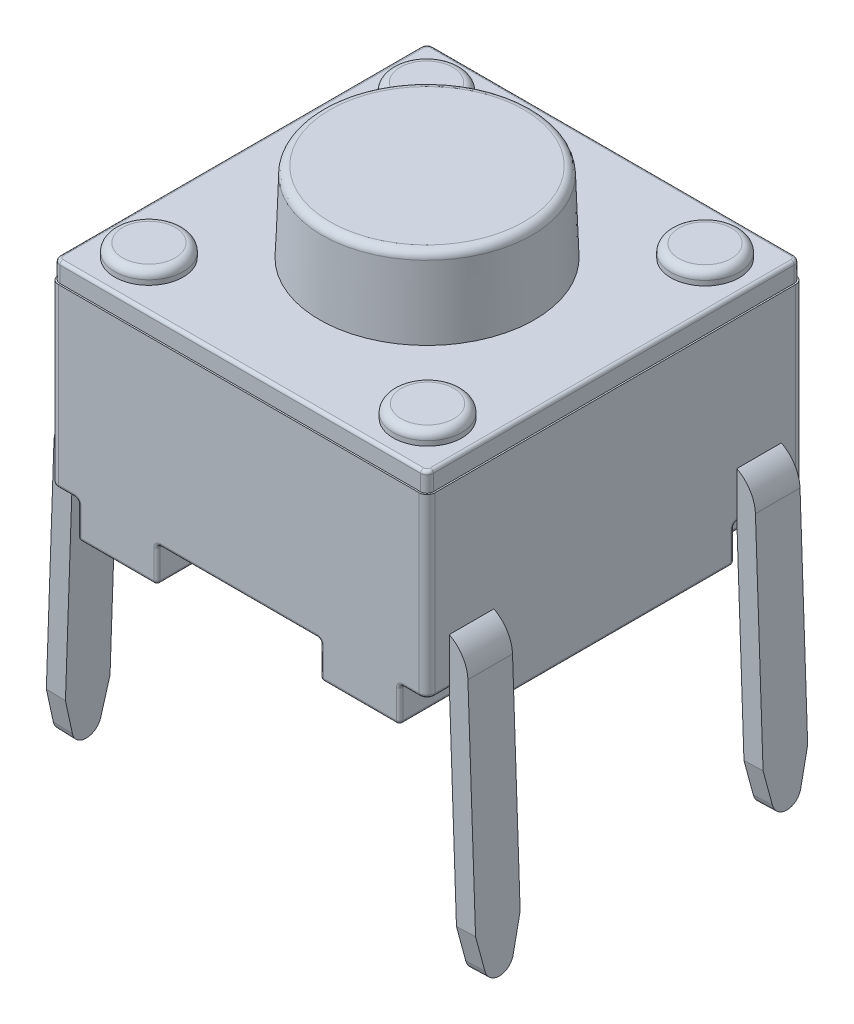
from build123d import *

# Parameters (mm, degrees)
BOSS_EXTRUDE1_START  = 0.5588
SKETCH1_W            = 6.0071
SKETCH1_H            = 6.0071
BOSS_EXTRUDE1_DEPTH  = 2.8194
FILLET1_R            = 0.127
BOSS_EXTRUDE2_DEPTH  = 0.3048
BOSS_EXTRUDE3_REACH  = 7.622
SKETCH4_R            = 0.5461
BOSS_EXTRUDE4_DEPTH  = 0.2032
SKETCH5_R            = 1.7145
BOSS_EXTRUDE5_DEPTH  = 1.27
BOSS_EXTRUDE5_TAPER  = 2
FILLET2_R            = 0.127
FILLET3_R            = 0.0508
EXTRUDE_THIN1_START  = -0.3556
EXTRUDE_THIN1_DEPTH  = 0.7112
CUT_EXTRUDE1_DEPTH   = 0.7112
MIRROR3_START        = -0.3556
MIRROR3_COPY_1_DEPTH = 0.7112
MIRROR3_COPY_2_DEPTH = 0.7112


with BuildPart() as part:
    # Sketch1 → Boss-Extrude1 (new body)
    with BuildSketch(Plane(origin=(0, 0, 0), x_dir=(1, 0, 0), z_dir=(0, 1, 0)).offset(BOSS_EXTRUDE1_START)):
        Rectangle(SKETCH1_W, SKETCH1_H)
    extrude(amount=BOSS_EXTRUDE1_DEPTH)

    # Fillet1
    fillet1_edges = [part.edges().sort_by_distance(p)[0] for p in [
        (3.00355, 1.9685, 3.00355),
        (-3.00355, 1.9685, 3.00355),
        (-3.00355, 1.9685, -3.00355),
        (3.00355, 1.9685, -3.00355),
    ]]
    fillet(fillet1_edges, radius=FILLET1_R)

    # Sketch2 → Boss-Extrude2 (add)
    with BuildSketch(Plane(origin=(0, 3.3782, 0), x_dir=(-1, 0, 0), z_dir=(0, -1, 0))):
        with BuildLine():
            Line((2.97815, -2.87655), (2.97815, 2.87655))
            ThreePointArc((2.97815, 2.87655), (2.948392049, 2.948392049), (2.87655, 2.97815))
            Line((2.87655, 2.97815), (-2.87655, 2.97815))
            ThreePointArc((-2.87655, 2.97815), (-2.948392049, 2.948392049), (-2.97815, 2.87655))
            Line((-2.97815, 2.87655), (-2.97815, -2.87655))
            ThreePointArc((-2.97815, -2.87655), (-2.948392049, -2.948392049), (-2.87655, -2.97815))
            Line((-2.87655, -2.97815), (2.87655, -2.97815))
            ThreePointArc((2.87655, -2.97815), (2.948392049, -2.948392049), (2.97815, -2.87655))
        make_face()
    extrude(amount=-BOSS_EXTRUDE2_DEPTH)

    # Sketch3 → Boss-Extrude3 (add, up to next)
    with BuildSketch(Plane(origin=(0, 0, 0), x_dir=(1, 0, 0), z_dir=(0, 1, 0)), mode=Mode.PRIVATE) as boss_extrude3_sk1:
        Polygon((-2.566197678, -3.00355), (-2.566197678, -1.89483443), (-3.00355, -1.89483443), (-3.00355, 1.89483443), (-2.566197678, 1.89483443), (-2.566197678, 3.00355), (-1.30175, 3.00355), (-1.30175, 0.560941661), (-2.441300776, 0.560941661), (-2.441300776, -0.560941661), (-1.30175, -0.560941661), (-1.30175, -3.00355), align=None)
    boss_extrude3_tool1 = extrude(boss_extrude3_sk1.sketch, amount=BOSS_EXTRUDE3_REACH, mode=Mode.PRIVATE) - part.part
    # Sketch3 → Boss-Extrude3 (add, up to next)
    with BuildSketch(Plane(origin=(0, 0, 0), x_dir=(1, 0, 0), z_dir=(0, 1, 0)), mode=Mode.PRIVATE) as boss_extrude3_sk2:
        Polygon((2.566197678, 3.00355), (2.566197678, 1.89483443), (3.00355, 1.89483443), (3.00355, -1.89483443), (2.566197678, -1.89483443), (2.566197678, -3.00355), (1.30175, -3.00355), (1.30175, -0.560941661), (2.441300776, -0.560941661), (2.441300776, 0.560941661), (1.30175, 0.560941661), (1.30175, 3.00355), align=None)
    boss_extrude3_tool2 = extrude(boss_extrude3_sk2.sketch, amount=BOSS_EXTRUDE3_REACH, mode=Mode.PRIVATE) - part.part
    add(boss_extrude3_tool1.solids().sort_by_distance((-2.503763, 0, 2.449192))[0])
    add(boss_extrude3_tool2.solids().sort_by_distance((2.503763, 0, -2.449192))[0])

    # Sketch4 → Boss-Extrude4 (add)
    with BuildSketch(Plane(origin=(0, 3.683, 0), x_dir=(1, 0, 0), z_dir=(0, 1, 0))):
        with Locations(Location((2.221694311, 2.212885437, 0), (0, 0, 90))):
            Circle(SKETCH4_R)
        with Locations(Location((-2.221694311, 2.212885437, 0), (0, 0, 90))):
            Circle(SKETCH4_R)
        with Locations(Location((-2.221694311, -2.212885437, 0), (0, 0, 90))):
            Circle(SKETCH4_R)
        with Locations(Location((2.221694311, -2.212885437, 0), (0, 0, 90))):
            Circle(SKETCH4_R)
    extrude(amount=BOSS_EXTRUDE4_DEPTH)

    # Sketch5 → Boss-Extrude5 (add)
    with BuildSketch(Plane(origin=(0, 3.683, 0), x_dir=(1, 0, 0), z_dir=(0, 1, 0))):
        Circle(SKETCH5_R)
    extrude(amount=BOSS_EXTRUDE5_DEPTH, taper=BOSS_EXTRUDE5_TAPER)

    # Fillet2
    fillet2_edges = [part.edges().sort_by_distance(p)[0] for p in [
        (2.221694311, 3.8862, -1.666785437),
        (-2.221694311, 3.8862, -1.666785437),
        (-2.221694311, 3.8862, 2.758985437),
        (2.221694311, 3.8862, 2.758985437),
        (-1.670150623, 4.953, 0),
    ]]
    fillet(fillet2_edges, radius=FILLET2_R)

    # Fillet3
    fillet3_edges = [part.edges().sort_by_distance(p)[0] for p in [
        (1.30175, 0.5588, -1.782245831),
        (1.30175, 0.2794, -3.00355),
        (1.30175, 0, -1.782245831),
        (1.871525388, 0.5588, -0.560941661),
        (1.30175, 0.2794, -0.560941661),
        (1.871525388, 0, -0.560941661),
        (2.441300776, 0.5588, 0),
        (2.441300776, 0.2794, -0.560941661),
        (2.441300776, 0, 0),
        (1.871525388, 0.5588, 0.560941661),
        (2.441300776, 0.2794, 0.560941661),
        (1.871525388, 0, 0.560941661),
        (1.30175, 0.5588, 1.782245831),
        (1.30175, 0.2794, 0.560941661),
        (1.30175, 0, 1.782245831),
        (1.30175, 0.2794, 3.00355),
        (1.933973839, 0, 3.00355),
        (2.566197678, 0.5588, 2.449192215),
        (2.566197678, 0.2794, 3.00355),
        (2.566197678, 0, 2.449192215),
        (2.784873839, 0.5588, 1.89483443),
        (2.566197678, 0.2794, 1.89483443),
        (2.784873839, 0, 1.89483443),
        (3.00355, 0.2794, 1.89483443),
        (3.00355, 0, 0),
        (2.784873839, 0.5588, -1.89483443),
        (3.00355, 0.2794, -1.89483443),
        (2.784873839, 0, -1.89483443),
        (2.566197678, 0.2794, -3.00355),
        (1.933973839, 0, -3.00355),
        (2.566197678, 0.5588, -2.449192215),
        (2.566197678, 0.2794, -1.89483443),
        (2.566197678, 0, -2.449192215),
        (-2.721373839, 0.5588, 3.00355),
        (3.00355, 0.5588, 2.385692215),
        (-3.00355, 0.5588, -2.385692215),
        (2.721373839, 0.5588, -3.00355),
        (2.966352561, 0.5588, 2.966352561),
        (2.966352561, 0.5588, -2.966352561),
        (-2.966352561, 0.5588, -2.966352561),
        (-2.966352561, 0.5588, 2.966352561),
        (-2.948392049, 3.683, 2.948392049),
        (0, 3.683, 2.97815),
        (2.948392049, 3.683, 2.948392049),
        (2.97815, 3.683, 0),
        (2.948392049, 3.683, -2.948392049),
        (0, 3.683, -2.97815),
        (-2.948392049, 3.683, -2.948392049),
        (-2.97815, 3.683, 0),
        (0, 0.5588, 3.00355),
        (-3.00355, 0.5588, 2.385692215),
        (-2.721373839, 0.5588, -3.00355),
        (-1.30175, 0.5588, 1.782245831),
        (-1.30175, 0.2794, 3.00355),
        (-1.30175, 0, 1.782245831),
        (-1.871525388, 0.5588, 0.560941661),
        (-1.30175, 0.2794, 0.560941661),
        (-1.871525388, 0, 0.560941661),
        (-2.441300776, 0.5588, 0),
        (-2.441300776, 0.2794, 0.560941661),
        (-2.441300776, 0, 0),
        (-1.871525388, 0.5588, -0.560941661),
        (-2.441300776, 0.2794, -0.560941661),
        (-1.871525388, 0, -0.560941661),
        (-1.30175, 0.5588, -1.782245831),
        (-1.30175, 0.2794, -0.560941661),
        (-1.30175, 0, -1.782245831),
        (-1.30175, 0.2794, -3.00355),
        (-1.933973839, 0, -3.00355),
        (-2.566197678, 0.5588, -2.449192215),
        (-2.566197678, 0.2794, -3.00355),
        (-2.566197678, 0, -2.449192215),
        (-2.784873839, 0.5588, -1.89483443),
        (-2.566197678, 0.2794, -1.89483443),
        (-2.784873839, 0, -1.89483443),
        (-3.00355, 0.2794, -1.89483443),
        (-3.00355, 0, 0),
        (-2.784873839, 0.5588, 1.89483443),
        (-3.00355, 0.2794, 1.89483443),
        (-2.784873839, 0, 1.89483443),
        (-2.566197678, 0.2794, 3.00355),
        (-1.933973839, 0, 3.00355),
        (-2.566197678, 0.5588, 2.449192215),
        (-2.566197678, 0.2794, 1.89483443),
        (-2.566197678, 0, 2.449192215),
        (0, 0.5588, -3.00355),
        (3.00355, 0.5588, -2.385692215),
        (2.721373839, 0.5588, 3.00355),
    ]]
    fillet(fillet3_edges, radius=FILLET3_R)

    # Sketch6 → Extrude-Thin1 (add)
    with BuildSketch(Plane.XY.offset(3.00355).offset(EXTRUDE_THIN1_START)):
        with BuildLine():
            Line((-2.526489479, 1.064092226), (-2.74199854, 1.064092226))
            ThreePointArc((-2.74199854, 1.064092226), (-2.918441767, 0.992804535), (-2.995843811, 0.818956698))
            Line((-2.995843811, 0.818956698), (-3.042276717, -0.510707774))
            Line((-3.042276717, -0.510707774), (-3.113192494, -2.541469934))
            Line((-3.113192494, -2.541469934), (-3.142411752, -3.3782))
            Line((-3.142411752, -3.3782), (-3.447026076, -3.367562633))
            Line((-3.447026076, -3.367562633), (-3.417806818, -2.530832568))
            Line((-3.417806818, -2.530832568), (-3.346891041, -0.500070407))
            Line((-3.346891041, -0.500070407), (-3.300458135, 0.829594065))
            ThreePointArc((-3.300458135, 0.829594065), (-3.130173638, 1.212059307), (-2.74199854, 1.368892226))
            Line((-2.74199854, 1.368892226), (-2.526489479, 1.368892226))
            Line((-2.526489479, 1.368892226), (-2.526489479, 1.064092226))
        make_face()
    extrude_thin1 = extrude(amount=-EXTRUDE_THIN1_DEPTH)

    # Sketch9 → Cut-Extrude1 (cut)
    with BuildSketch(Plane(origin=(-3.325373038, 0.116124585, 0), x_dir=(0, 0, 1), z_dir=(-0.9993908270190955, 0.034899496702504834, 0))):
        with BuildLine():
            Line((2.64795, -3.48581068), (2.64795, -2.776578932))
            Line((2.64795, -2.776578932), (2.517535772, -3.30911696))
            ThreePointArc((2.517535772, -3.30911696), (2.435466476, -3.436364343), (2.29235, -3.48581068))
            Line((2.29235, -3.48581068), (2.64795, -3.48581068))
        make_face()
        with BuildLine():
            Line((1.93675, -3.48581068), (2.29235, -3.48581068))
            ThreePointArc((2.29235, -3.48581068), (2.149233524, -3.436364343), (2.067164228, -3.30911696))
            Line((2.067164228, -3.30911696), (1.93675, -2.776578932))
            Line((1.93675, -2.776578932), (1.93675, -3.48581068))
        make_face()
    cut_extrude1 = extrude(amount=-CUT_EXTRUDE1_DEPTH, mode=Mode.SUBTRACT)

    # Mirror1: Extrude-Thin1, Cut-Extrude1 across plane
    add(extrude_thin1.mirror(Plane.XY))
    add(cut_extrude1.mirror(Plane.XY), mode=Mode.SUBTRACT)

    # Mirror3: Extrude-Thin1, Cut-Extrude1 across plane
    add(extrude_thin1.mirror(Plane(origin=(0, 0, 0), x_dir=(0, 0, 1), z_dir=(1, 0, 0))))
    add(cut_extrude1.mirror(Plane(origin=(0, 0, 0), x_dir=(0, 0, 1), z_dir=(1, 0, 0))), mode=Mode.SUBTRACT)

    # Mirror3 copy 1 sketch → Mirror3 copy 1 (add)
    with BuildSketch(Plane(origin=(0, 0, -3.00355), x_dir=(-1, 0, 0), z_dir=(0, 0, -1)).offset(MIRROR3_START)):
        with BuildLine():
            Line((-2.526489479, 1.064092226), (-2.74199854, 1.064092226))
            ThreePointArc((-2.74199854, 1.064092226), (-2.918441767, 0.992804535), (-2.995843811, 0.818956698))
            Line((-2.995843811, 0.818956698), (-3.042276717, -0.510707774))
            Line((-3.042276717, -0.510707774), (-3.113192494, -2.541469934))
            Line((-3.113192494, -2.541469934), (-3.142411752, -3.3782))
            Line((-3.142411752, -3.3782), (-3.447026076, -3.367562633))
            Line((-3.447026076, -3.367562633), (-3.417806818, -2.530832568))
            Line((-3.417806818, -2.530832568), (-3.346891041, -0.500070407))
            Line((-3.346891041, -0.500070407), (-3.300458135, 0.829594065))
            ThreePointArc((-3.300458135, 0.829594065), (-3.130173638, 1.212059307), (-2.74199854, 1.368892226))
            Line((-2.74199854, 1.368892226), (-2.526489479, 1.368892226))
            Line((-2.526489479, 1.368892226), (-2.526489479, 1.064092226))
        make_face()
    extrude(amount=-MIRROR3_COPY_1_DEPTH)

    # Mirror3 copy 2 sketch → Mirror3 copy 2 (cut)
    with BuildSketch(Plane(origin=(3.325373038, 0.116124585, 0), x_dir=(0, 0, -1), z_dir=(0.9993908270190955, 0.034899496702504834, 0))):
        with BuildLine():
            Line((2.64795, -3.48581068), (2.64795, -2.776578932))
            Line((2.64795, -2.776578932), (2.517535772, -3.30911696))
            ThreePointArc((2.517535772, -3.30911696), (2.435466476, -3.436364343), (2.29235, -3.48581068))
            Line((2.29235, -3.48581068), (2.64795, -3.48581068))
        make_face()
        with BuildLine():
            Line((1.93675, -3.48581068), (2.29235, -3.48581068))
            ThreePointArc((2.29235, -3.48581068), (2.149233524, -3.436364343), (2.067164228, -3.30911696))
            Line((2.067164228, -3.30911696), (1.93675, -2.776578932))
            Line((1.93675, -2.776578932), (1.93675, -3.48581068))
        make_face()
    extrude(amount=-MIRROR3_COPY_2_DEPTH, mode=Mode.SUBTRACT)


solid = part.part
